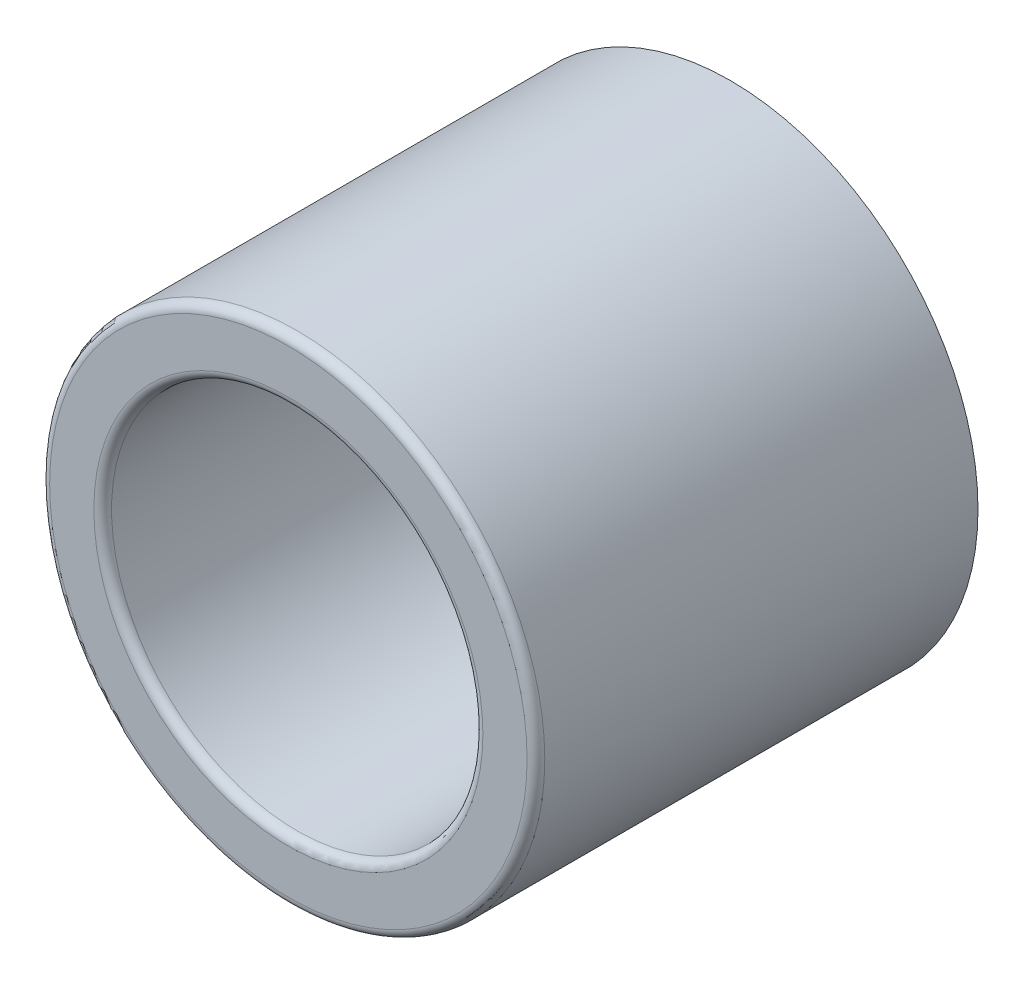
from build123d import *

# Parameters (mm, degrees)
SKETCH1_R           = 2.8
SKETCH1_R_2         = 2.1
BOSS_EXTRUDE1_DEPTH = 5
FILLET1_R           = 0.1


with BuildPart() as part:
    # Sketch1 → Boss-Extrude1 (new body)
    with BuildSketch(Plane.XY):
        Circle(SKETCH1_R)
        Circle(SKETCH1_R_2, mode=Mode.SUBTRACT)
    extrude(amount=BOSS_EXTRUDE1_DEPTH)

    # Fillet1
    fillet1_edges = [part.edges().sort_by_distance(p)[0] for p in [
        (-2.8, 0, 5),
        (-2.1, 0, 5),
    ]]
    fillet(fillet1_edges, radius=FILLET1_R)


solid = part.part
